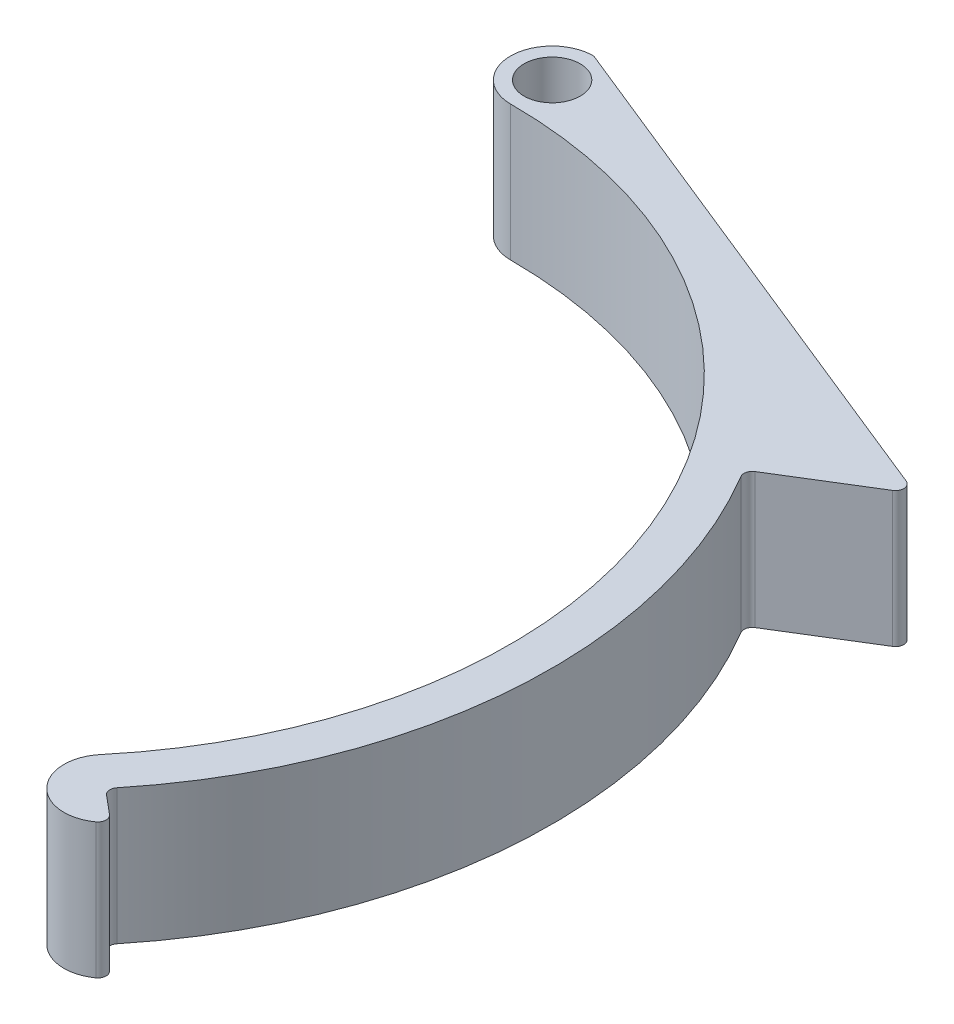
from build123d import *

# Parameters (mm, degrees)
SKETCH1_R           = 2.7
BOSS_EXTRUDE1_DEPTH = 13
FILLET1_R           = 0.8


with BuildPart() as part:
    # Sketch1 → Boss-Extrude1 (new body)
    with BuildSketch(Plane(origin=(0, 0, 0), x_dir=(1, 0, 0), z_dir=(0, 1, 0))):
        with BuildLine():
            Line((51.921017872, 32.018867925), (0, 53))
            ThreePointArc((0, 53), (-4, 49), (0, 45))
            ThreePointArc((0, 45), (40.783850417, 19.017821778), (34.47199994, -28.925442436))
            ThreePointArc((34.47199994, -28.925442436), (34.965027274, -34.560770647), (40.600355485, -34.067743313))
            Line((40.600355485, -34.067743313), (37.536177713, -31.496592875))
            ThreePointArc((37.536177713, -31.496592875), (48.870327604, -3.562454189), (41.707047143, 25.720074234))
            Line((41.707047143, 25.720074234), (51.921017872, 32.018867925))
        make_face()
        with Locations((0, 49)):
            Circle(SKETCH1_R, mode=Mode.SUBTRACT)
    extrude(amount=BOSS_EXTRUDE1_DEPTH)

    # Fillet1
    fillet1_edges = [part.edges().sort_by_distance(p)[0] for p in [
        (51.921017872, 6.5, -32.018867925),
        (41.707047143, 6.5, -25.720074234),
        (37.536177713, 6.5, 31.496592875),
        (40.600355485, 6.5, 34.067743313),
        (0, 6.5, -53),
    ]]
    fillet(fillet1_edges, radius=FILLET1_R)


solid = part.part
